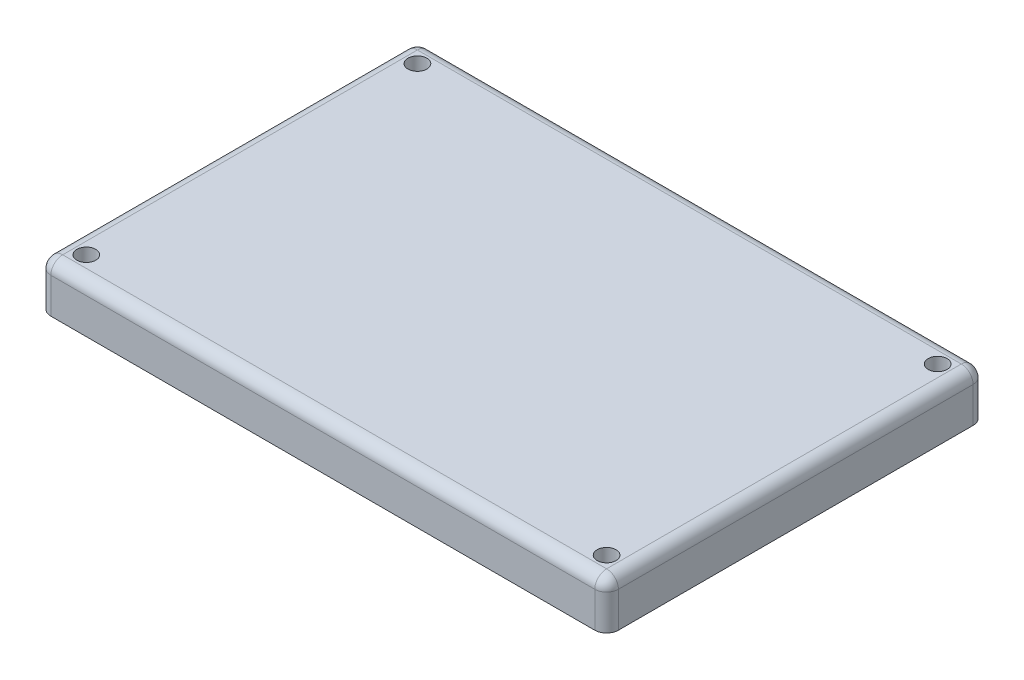
from build123d import *

# Parameters (mm, degrees)
SKETCH1_W           = 60.96
SKETCH1_H           = 40.64
BOSS_EXTRUDE1_DEPTH = 5.08
SHELL1_T            = -2.54
SKETCH2_R           = 2.54
BOSS_EXTRUDE2_DEPTH = 5.08
SKETCH3_R           = 1.016
CUT_EXTRUDE1_DEPTH  = 5.08
FILLET2_R           = 1.27


with BuildPart() as part:
    # Sketch1 → Boss-Extrude1 (new body)
    with BuildSketch(Plane(origin=(0, 0, 0), x_dir=(1, 0, 0), z_dir=(0, 1, 0))):
        with Locations((30.48, 20.32)):
            Rectangle(SKETCH1_W, SKETCH1_H)
    extrude(amount=BOSS_EXTRUDE1_DEPTH)

    # Shell1
    shell1_openings = [part.faces().sort_by_distance(p)[0] for p in [
        (30.48, 0, -20.32),
    ]]
    offset(amount=SHELL1_T, openings=shell1_openings, kind=Kind.INTERSECTION)

    # Sketch2 → Boss-Extrude2 (add)
    with BuildSketch(Plane.XZ):
        with Locations((58.42, -38.1)):
            Circle(SKETCH2_R)
        with Locations((58.42, -2.54)):
            Circle(SKETCH2_R)
        with Locations((2.54, -2.54)):
            Circle(SKETCH2_R)
        with Locations((2.54, -38.1)):
            Circle(SKETCH2_R)
    extrude(amount=-BOSS_EXTRUDE2_DEPTH)

    # Sketch3 → Cut-Extrude1 (cut)
    with BuildSketch(Plane.XZ):
        with Locations((58.42, -38.1)):
            Circle(SKETCH3_R)
        with Locations((58.42, -2.54)):
            Circle(SKETCH3_R)
        with Locations((2.54, -2.54)):
            Circle(SKETCH3_R)
        with Locations((2.54, -38.1)):
            Circle(SKETCH3_R)
    extrude(amount=-CUT_EXTRUDE1_DEPTH, mode=Mode.SUBTRACT)

    # Fillet2
    fillet2_edges = [part.edges().sort_by_distance(p)[0] for p in [
        (60.96, 5.08, -20.32),
        (30.48, 5.08, -40.64),
        (0, 5.08, -20.32),
        (30.48, 5.08, 0),
        (0, 2.54, -40.64),
        (60.96, 2.54, -40.64),
        (60.96, 2.54, 0),
        (0, 2.54, 0),
    ]]
    fillet(fillet2_edges, radius=FILLET2_R)


solid = part.part
